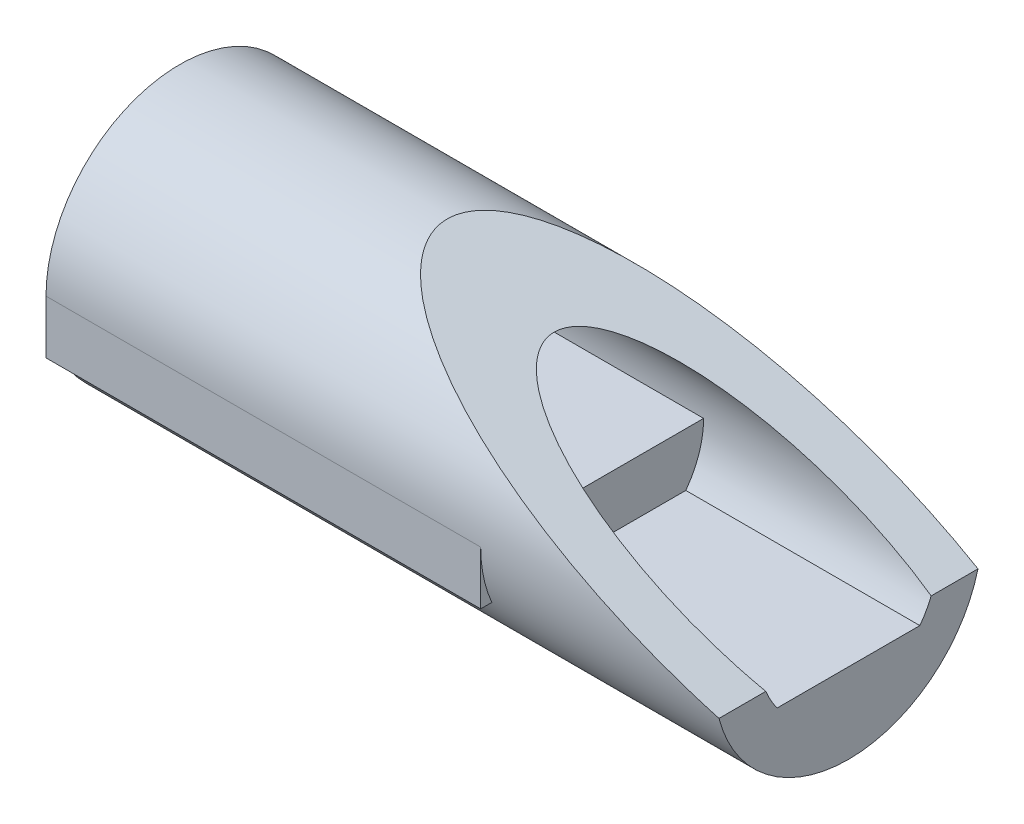
from build123d import *

# Parameters (mm, degrees)
SKETCH1_R               = 20
BOSS_EXTRUDE1_DEPTH     = 100
SKETCH2_W               = 65
SKETCH2_H               = 9.328019595
SKETCH2_H_2             = 21.34396081
BOSS_EXTRUDE2_DEPTH     = 8
CUT_EXTRUDE2_DEPTH      = 21
CUT_EXTRUDE2_DEPTH_BACK = 21


with BuildPart() as part:
    # Sketch1 → Boss-Extrude1 (new body)
    with BuildSketch(Plane(origin=(0, 0, 0), x_dir=(0, 0, -1), z_dir=(1, 0, 0))):
        Circle(SKETCH1_R)
        with BuildLine():
            Line((-10.671980405, -8), (10.671980405, -8))
            ThreePointArc((10.671980405, -8), (0, 13.337584705), (-10.671980405, -8))
        make_face(mode=Mode.SUBTRACT)
    extrude(amount=-BOSS_EXTRUDE1_DEPTH)

    # Sketch2 → Boss-Extrude2 (add)
    with BuildSketch(Plane(origin=(0, -8, 0), x_dir=(1, 0, 0), z_dir=(0, 1, 0))):
        with Locations((-67.5, 15.335990202)):
            Rectangle(SKETCH2_W, SKETCH2_H)
        with Locations((-67.5, 0)):
            Rectangle(SKETCH2_W, SKETCH2_H_2)
        with Locations((-67.5, -15.335990202)):
            Rectangle(SKETCH2_W, SKETCH2_H)
    extrude(amount=BOSS_EXTRUDE2_DEPTH)

    # Sketch3 → Cut-Extrude2 (cut, two sides)
    with BuildSketch(Plane.XY) as cut_extrude2_sk:
        Polygon((0, 20), (-60, 20), (0, -5), align=None)
    extrude(amount=CUT_EXTRUDE2_DEPTH, mode=Mode.SUBTRACT)
    extrude(cut_extrude2_sk.sketch, amount=-CUT_EXTRUDE2_DEPTH_BACK, mode=Mode.SUBTRACT)


solid = part.part
